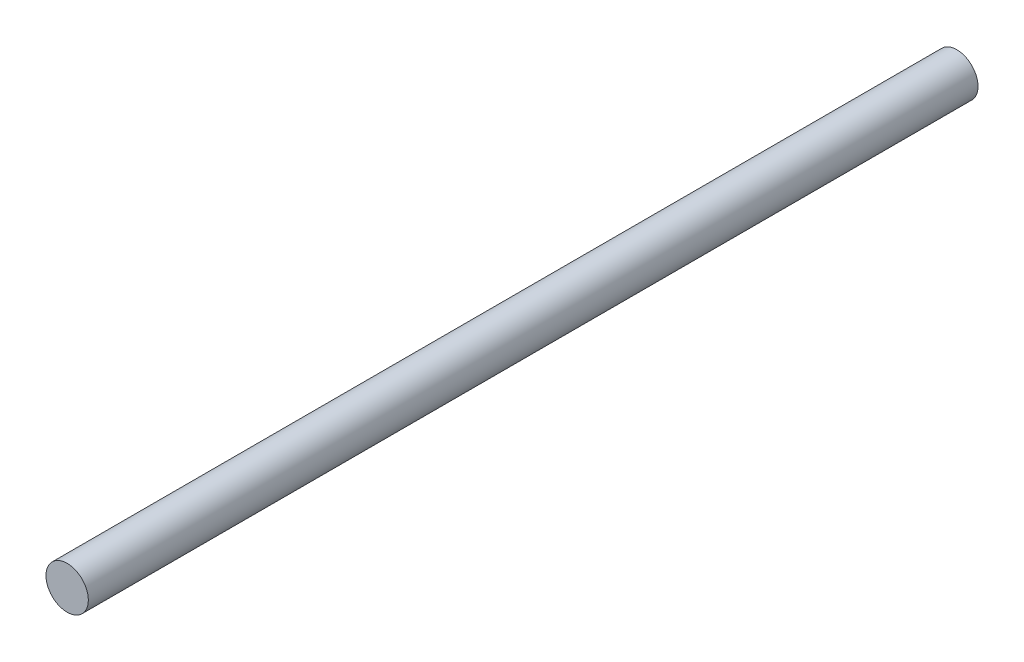
from build123d import *

# Parameters (mm, degrees)
SKETCH1_R           = 0.5
BOSS_EXTRUDE1_DEPTH = 21


with BuildPart() as part:
    # Sketch1 → Boss-Extrude1 (new body)
    with BuildSketch(Plane.XY):
        Circle(SKETCH1_R)
    extrude(amount=BOSS_EXTRUDE1_DEPTH)


solid = part.part
